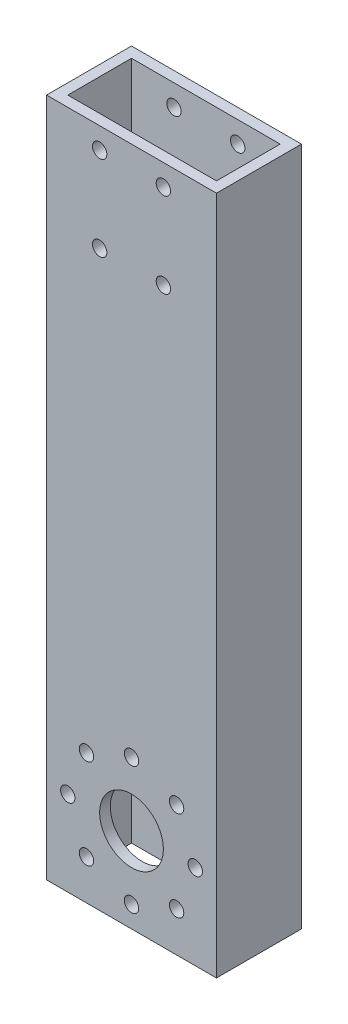
from build123d import *

# Parameters (mm, degrees)
SKETCH2_W                = 50.8
SKETCH2_H                = 25.4
SKETCH2_W_2              = 44.45
SKETCH2_H_2              = 19.05
EXTRUDE_THIN1_DEPTH      = 457.2
SKETCH25_W               = 50.8
SKETCH25_H               = 25.4
SKETCH25_W_2             = 44.45
SKETCH25_H_2             = 19.05
BOSS_EXTRUDE14_DEPTH     = 25.4
SKETCH29_W               = 50.8
SKETCH29_H               = 25.4
SKETCH29_W_2             = 44.45
SKETCH29_H_2             = 19.05
CUT_EXTRUDE10_DEPTH      = 203.2
SKETCH34_R               = 9.525
SKETCH34_R_2             = 2.15265
CUT_EXTRUDE15_DEPTH      = 25.4
SKETCH35_W               = 50.8
SKETCH35_H               = 25.4
CUT_EXTRUDE16_DEPTH      = 76.2
SKETCH31_R               = 2.15265
CUT_EXTRUDE12_DEPTH      = 1
CUT_EXTRUDE12_DEPTH_BACK = 26.4


with BuildPart() as part:
    # Sketch2 → Extrude-Thin1 (new body)
    with BuildSketch(Plane(origin=(0, 0, 0), x_dir=(1, 0, 0), z_dir=(0, 1, 0))):
        with Locations((10.213756614, 0.671957672)):
            Rectangle(SKETCH2_W, SKETCH2_H)
        with Locations((10.213756614, 0.671957672)):
            Rectangle(SKETCH2_W_2, SKETCH2_H_2, mode=Mode.SUBTRACT)
    extrude(amount=EXTRUDE_THIN1_DEPTH)

    # Sketch25 → Boss-Extrude14 (add)
    with BuildSketch(Plane.XZ):
        with Locations((10.213756614, -0.671957672)):
            Rectangle(SKETCH25_W, SKETCH25_H)
        with Locations((10.213756614, -0.671957672)):
            Rectangle(SKETCH25_W_2, SKETCH25_H_2, mode=Mode.SUBTRACT)
    extrude(amount=BOSS_EXTRUDE14_DEPTH)

    # Sketch29 → Cut-Extrude10 (cut)
    with BuildSketch(Plane(origin=(0, 457.2, 0), x_dir=(1, 0, 0), z_dir=(0, 1, 0))):
        with Locations((10.213756614, 0.671957672)):
            Rectangle(SKETCH29_W, SKETCH29_H)
        with Locations((10.213756614, 0.671957672)):
            Rectangle(SKETCH29_W_2, SKETCH29_H_2, mode=Mode.SUBTRACT)
    extrude(amount=-CUT_EXTRUDE10_DEPTH, mode=Mode.SUBTRACT)

    # Sketch34 → Cut-Extrude15 (cut)
    with BuildSketch(Plane.XY.offset(12.028042328)):
        with Locations((10.213756614, 0)):
            Circle(SKETCH34_R)
        with Locations((29.263756614, 0)):
            Circle(SKETCH34_R_2)
        with Locations((23.684140795, 13.470384182)):
            Circle(SKETCH34_R_2)
        with Locations((10.213756614, 19.05)):
            Circle(SKETCH34_R_2)
        with Locations((-3.256627568, 13.470384182)):
            Circle(SKETCH34_R_2)
        with Locations((-8.836243386, 0)):
            Circle(SKETCH34_R_2)
        with Locations((-3.256627568, -13.470384182)):
            Circle(SKETCH34_R_2)
        with Locations((10.213756614, -19.05)):
            Circle(SKETCH34_R_2)
        with Locations((23.684140795, -13.470384182)):
            Circle(SKETCH34_R_2)
    extrude(amount=-CUT_EXTRUDE15_DEPTH, mode=Mode.SUBTRACT)

    # Sketch35 → Cut-Extrude16 (cut)
    with BuildSketch(Plane(origin=(0, 254, 0), x_dir=(1, 0, 0), z_dir=(0, 1, 0))):
        with Locations((10.213756614, 0.671957672)):
            Rectangle(SKETCH35_W, SKETCH35_H)
    extrude(amount=-CUT_EXTRUDE16_DEPTH, mode=Mode.SUBTRACT)

    # Sketch31 → Cut-Extrude12 (cut, two sides)
    with BuildSketch(Plane(origin=(0, 0, -13.371957672), x_dir=(-1, 0, 0), z_dir=(0, 0, -1))) as cut_extrude12_sk:
        with Locations((-19.738756614, 146.05)):
            Circle(SKETCH31_R)
        with Locations((-0.688756614, 146.05)):
            Circle(SKETCH31_R)
        with Locations((-19.738756614, 171.45)):
            Circle(SKETCH31_R)
        with Locations((-0.688756614, 171.45)):
            Circle(SKETCH31_R)
    extrude(amount=CUT_EXTRUDE12_DEPTH, mode=Mode.SUBTRACT)
    extrude(cut_extrude12_sk.sketch, amount=-CUT_EXTRUDE12_DEPTH_BACK, mode=Mode.SUBTRACT)


solid = part.part
